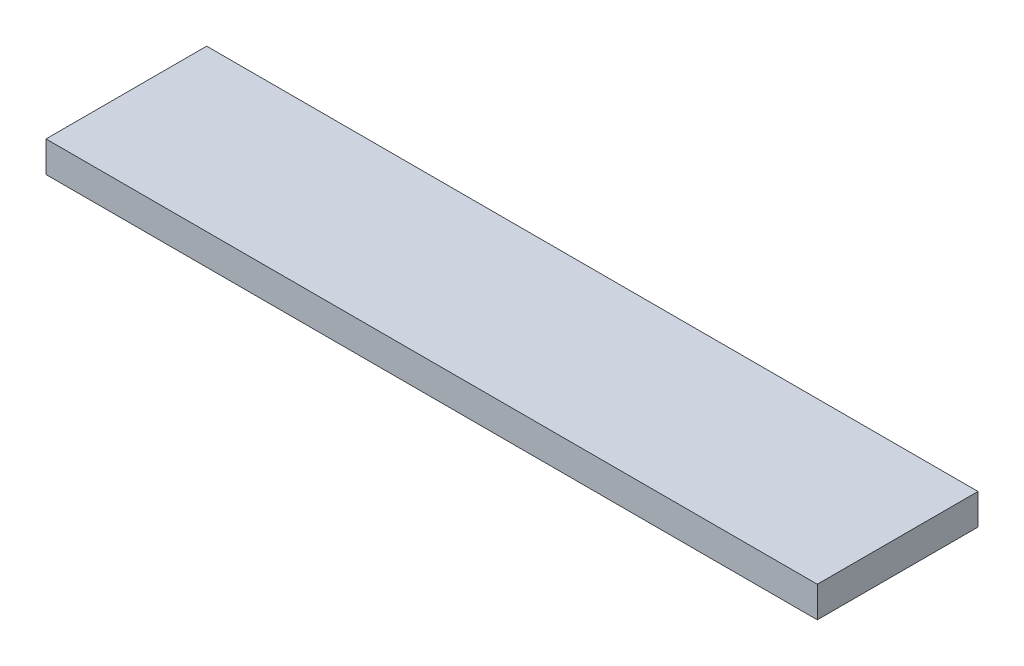
from build123d import *

# Parameters (mm, degrees)
SKETCH1_W           = 300
SKETCH1_H           = 62.5
BOSS_EXTRUDE1_DEPTH = 12


with BuildPart() as part:
    # Sketch1 → Boss-Extrude1 (new body)
    with BuildSketch(Plane(origin=(0, 0, 0), x_dir=(1, 0, 0), z_dir=(0, 1, 0))):
        Rectangle(SKETCH1_W, SKETCH1_H)
    extrude(amount=BOSS_EXTRUDE1_DEPTH)


solid = part.part
